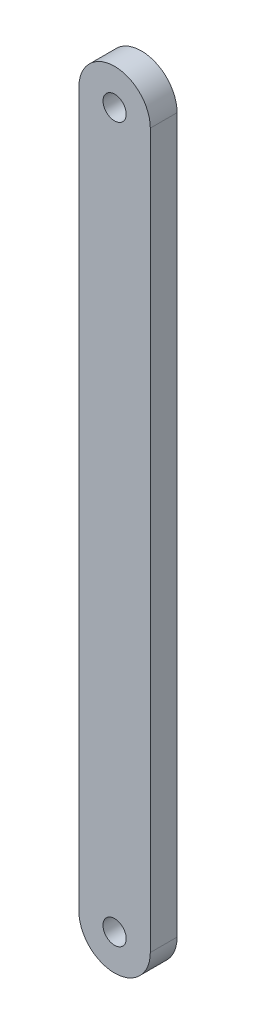
from build123d import *

# Parameters (mm, degrees)
MODEL_R             = 1.3
BOSS_EXTRUDE1_DEPTH = 3


with BuildPart() as part:
    # Model → Boss-Extrude1 (new body)
    with BuildSketch(Plane.XY):
        with BuildLine():
            Line((47.500099999, 80.00015), (47.500099999, 4.9999e-05))
            ThreePointArc((47.500099999, 4.9999e-05), (51.499999999, -3.99985), (55.499899998, 4.9999e-05))
            Line((55.499899998, 4.9999e-05), (55.499899998, 80.000050001))
            ThreePointArc((55.499899998, 80.000050001), (51.500049998, 84), (47.500099999, 80.00015))
        make_face()
        with Locations((51.500099998, 4.9998e-05)):
            Circle(MODEL_R, mode=Mode.SUBTRACT)
        with Locations((51.500099998, 80.000049998)):
            Circle(MODEL_R, mode=Mode.SUBTRACT)
    extrude(amount=BOSS_EXTRUDE1_DEPTH)


solid = part.part
